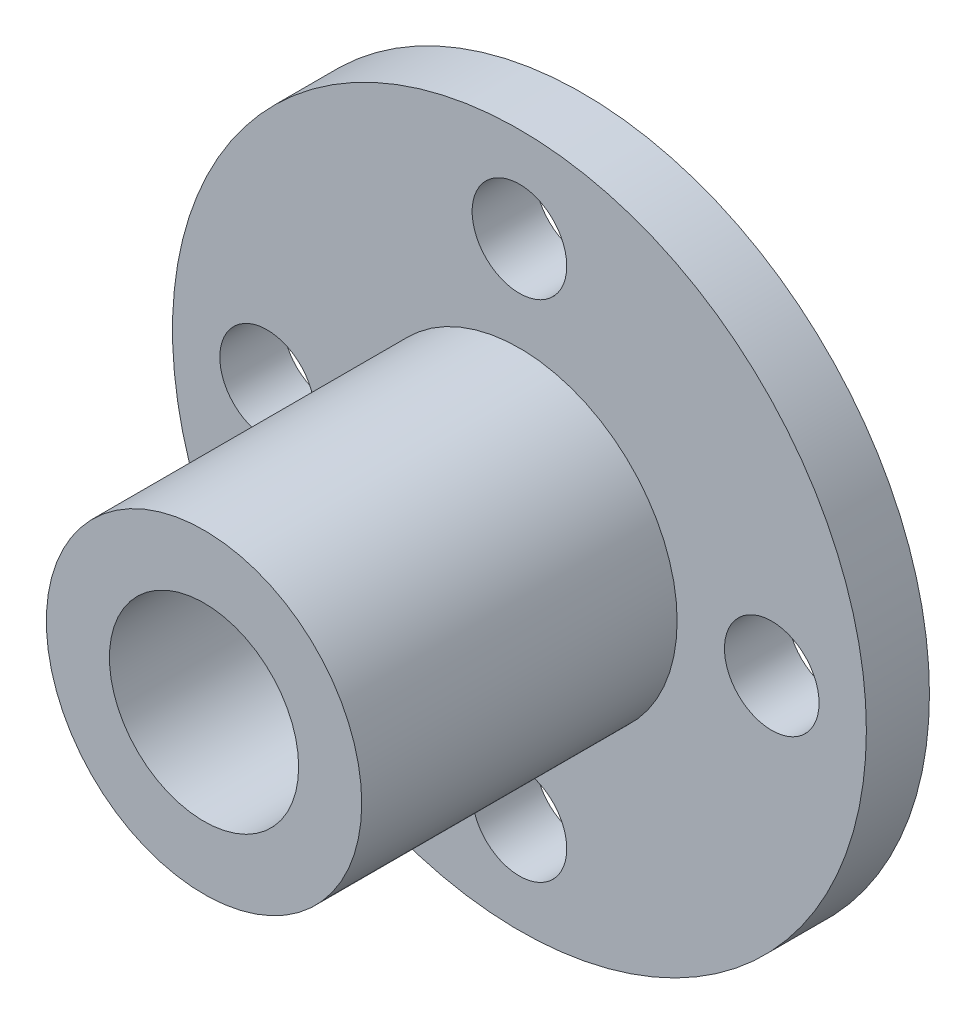
from build123d import *

# Parameters (mm, degrees)
SKETCH_1_R          = 11
EXTRUDE_1_DEPTH     = 2
SKETCH_2_R          = 5
EXTRUDE_2_DEPTH     = 10
SKETCH_4_R          = 3
CUT_EXTRUDE_2_DEPTH = 13
CUT_EXTRUDE_3_REACH = 4
SKETCH_5_R          = 1.5


with BuildPart() as part:
    # 草图1 → 凸台-拉伸1 (new body)
    with BuildSketch(Plane.XY):
        Circle(SKETCH_1_R)
    extrude(amount=EXTRUDE_1_DEPTH)

    # 草图2 → 凸台-拉伸2 (add)
    with BuildSketch(Plane.XY.offset(2)):
        Circle(SKETCH_2_R)
    extrude(amount=EXTRUDE_2_DEPTH)

    # 草图4 → 切除-拉伸2 (cut, through all)
    with BuildSketch(Plane.XY.offset(12)):
        Circle(SKETCH_4_R)
    extrude(amount=-CUT_EXTRUDE_2_DEPTH, mode=Mode.SUBTRACT)

    # 草图5 → 切除-拉伸3 (cut, up to next)
    with BuildSketch(Plane.XY.offset(2), mode=Mode.PRIVATE) as cut_extrude_3_sk1:
        with Locations((-8, 0)):
            Circle(SKETCH_5_R)
    cut_extrude_3_tool1 = extrude(cut_extrude_3_sk1.sketch, amount=-CUT_EXTRUDE_3_REACH, mode=Mode.PRIVATE) & part.part
    add(cut_extrude_3_tool1.solids().sort_by_distance((-8, 0, 2))[0], mode=Mode.SUBTRACT)
    # 草图5 → 切除-拉伸3 (cut, up to next)
    with BuildSketch(Plane.XY.offset(2), mode=Mode.PRIVATE) as cut_extrude_3_sk2:
        with Locations((0, 8)):
            Circle(SKETCH_5_R)
    cut_extrude_3_tool2 = extrude(cut_extrude_3_sk2.sketch, amount=-CUT_EXTRUDE_3_REACH, mode=Mode.PRIVATE) & part.part
    add(cut_extrude_3_tool2.solids().sort_by_distance((0, 8, 2))[0], mode=Mode.SUBTRACT)
    # 草图5 → 切除-拉伸3 (cut, up to next)
    with BuildSketch(Plane.XY.offset(2), mode=Mode.PRIVATE) as cut_extrude_3_sk3:
        with Locations((8, 0)):
            Circle(SKETCH_5_R)
    cut_extrude_3_tool3 = extrude(cut_extrude_3_sk3.sketch, amount=-CUT_EXTRUDE_3_REACH, mode=Mode.PRIVATE) & part.part
    add(cut_extrude_3_tool3.solids().sort_by_distance((8, 0, 2))[0], mode=Mode.SUBTRACT)
    # 草图5 → 切除-拉伸3 (cut, up to next)
    with BuildSketch(Plane.XY.offset(2), mode=Mode.PRIVATE) as cut_extrude_3_sk4:
        with Locations((0, -8)):
            Circle(SKETCH_5_R)
    cut_extrude_3_tool4 = extrude(cut_extrude_3_sk4.sketch, amount=-CUT_EXTRUDE_3_REACH, mode=Mode.PRIVATE) & part.part
    add(cut_extrude_3_tool4.solids().sort_by_distance((0, -8, 2))[0], mode=Mode.SUBTRACT)


solid = part.part
